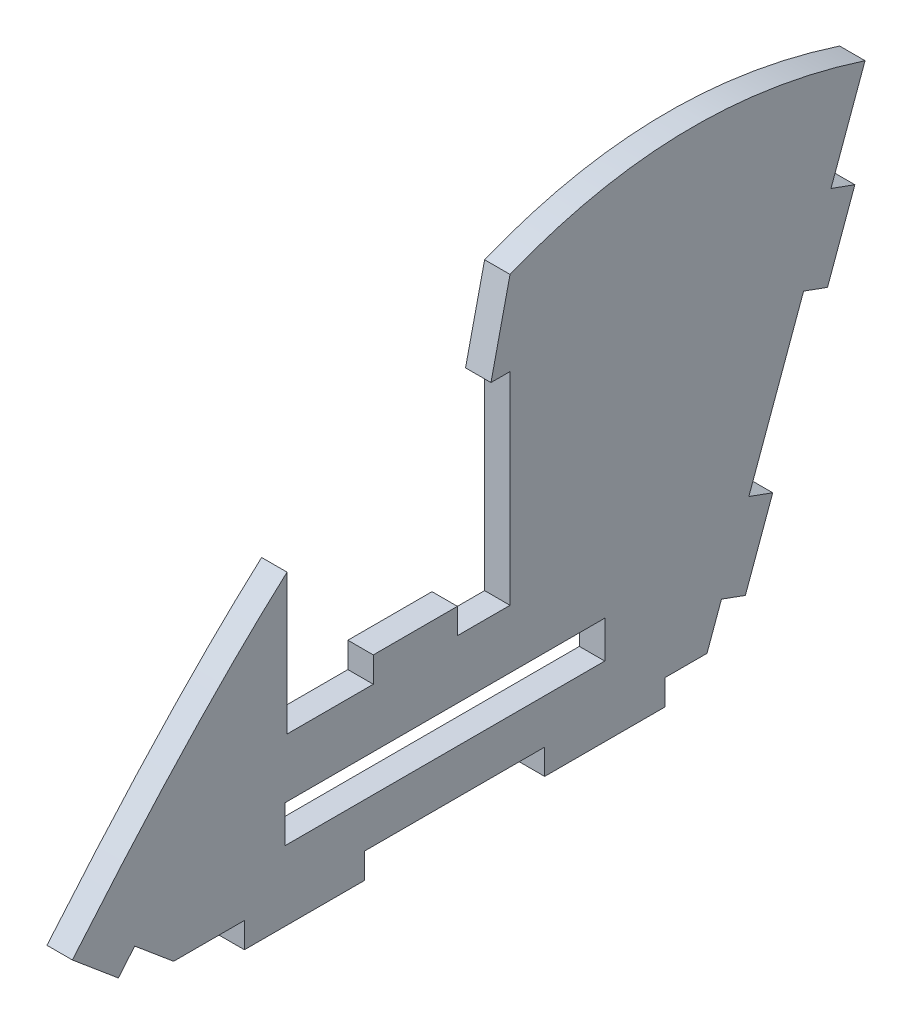
from build123d import *

# Parameters (mm, degrees)
BOSS_EXTRUDE1_DEPTH = 3.175
SKETCH2_W           = 27.85
SKETCH2_H           = 35.791497658
CUT_EXTRUDE1_DEPTH  = 4.1750001
SKETCH3_W           = 10.508
SKETCH3_H           = 3.175
BOSS_EXTRUDE2_DEPTH = 3.175
SKETCH4_W           = 22.5
SKETCH4_H           = 3.175
CUT_EXTRUDE2_DEPTH  = 4.1750001
SKETCH5_W           = 39.932212354
SKETCH5_H           = 4.644211625
CUT_EXTRUDE3_DEPTH  = 10


with BuildPart() as part:
    # Sketch1 → Boss-Extrude1 (new body)
    with BuildSketch(Plane(origin=(0, 0, 0), x_dir=(0, 0, -1), z_dir=(1, 0, 0))):
        with BuildLine():
            Line((0, 0), (70, 0))
            Line((70, 0), (90.5212086, 56.381557247))
            add(Edge.make_bspline(
                [(-11.490666647, 9.641814145), (19.4560829, 46.522714097), (48.01605029, 71.852169675), (90.5212086, 56.381557247)],
                knots=[0, 0, 0, 0, 1, 1, 1, 1], degree=3))
            Line((-11.490666647, 9.641814145), (0, 0))
        make_face()
    extrude(amount=BOSS_EXTRUDE1_DEPTH)

    # Sketch2 → Cut-Extrude1 (cut, through all)
    with BuildSketch(Plane.ZY):
        with Locations((-29.25, 38.570748829)):
            Rectangle(SKETCH2_W, SKETCH2_H)
    extrude(amount=-CUT_EXTRUDE1_DEPTH, mode=Mode.SUBTRACT)

    # Sketch3 → Boss-Extrude2 (add)
    with BuildSketch(Plane.ZY):
        Polygon((-43.175, 56.466497658), (-43.175, 45.958497658), (-40.79375, 45.958497658), align=None)
        with Locations((-31.35, 22.2625)):
            Rectangle(SKETCH3_W, SKETCH3_H)
    extrude(amount=-BOSS_EXTRUDE2_DEPTH)

    # Sketch4 → Cut-Extrude2 (cut, through all)
    with BuildSketch(Plane.ZY):
        Polygon((-83.262432737, 45.721313442), (-86.245956808, 44.635399487), (-90.5212086, 56.381557247), (-87.537684529, 57.467471202), align=None)
        Polygon((-79.842231304, 36.324387235), (-73.001828437, 17.530534819), (-75.985352508, 16.444620864), (-82.825755375, 35.238473279), align=None)
        Polygon((-72.565151075, 7.047694656), (-70, 0), (-62.5, 0), (-62.5, 3.175), (-67.776841066, 3.175), (-69.581627004, 8.133608611), align=None)
        with Locations((-36.25, 1.5875)):
            Rectangle(SKETCH4_W, SKETCH4_H)
        Polygon((-10, 3.175), (-10, 0), (0, 0), (5.745333323, 4.820907073), (3.704482663, 7.25309818), (-1.155605494, 3.175), align=None)
    extrude(amount=-CUT_EXTRUDE2_DEPTH, mode=Mode.SUBTRACT)

    # Sketch5 → Cut-Extrude3 (cut)
    with BuildSketch(Plane.ZY):
        with Locations((-35.043485806, 11.047370883)):
            Rectangle(SKETCH5_W, SKETCH5_H)
    extrude(amount=-CUT_EXTRUDE3_DEPTH, mode=Mode.SUBTRACT)


solid = part.part
